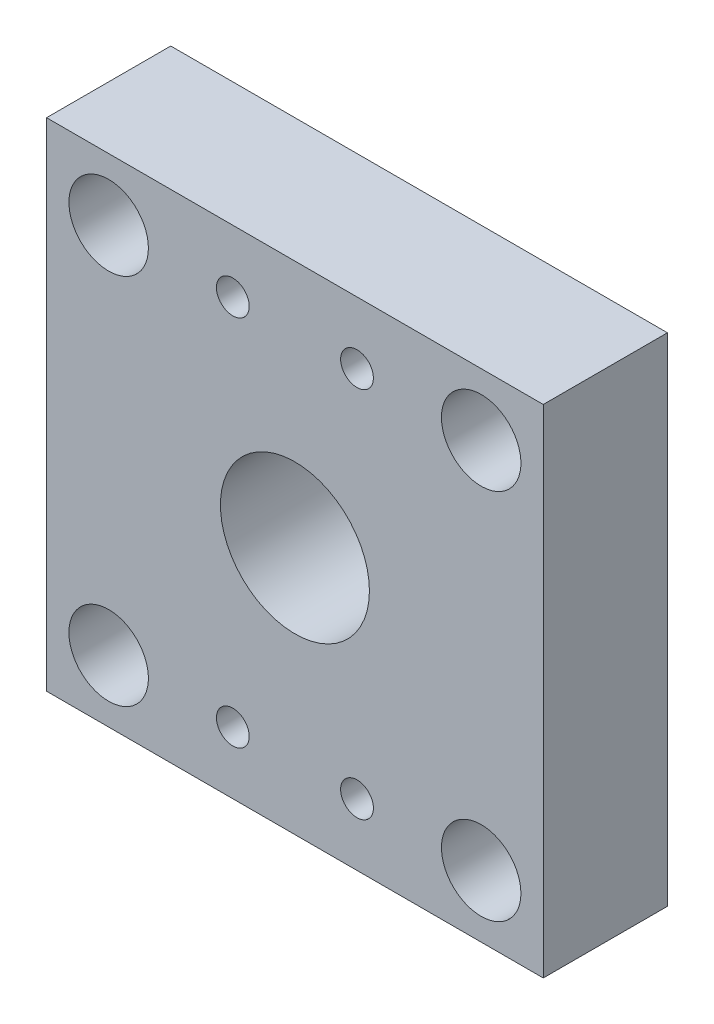
from build123d import *

# Parameters (mm, degrees)
SKETCH1_W           = 50.8
SKETCH1_H           = 50.8
BOSS_EXTRUDE1_DEPTH = 12.7
SKETCH2_R           = 7.62
CUT_EXTRUDE1_DEPTH  = 13.7
SKETCH3_R           = 4.064
CUT_EXTRUDE2_DEPTH  = 13.7
SKETCH4_R           = 1.6764
CUT_EXTRUDE3_DEPTH  = 13.7


with BuildPart() as part:
    # Sketch1 → Boss-Extrude1 (new body)
    with BuildSketch(Plane.XY):
        with Locations((25.4, 25.4)):
            Rectangle(SKETCH1_W, SKETCH1_H)
    extrude(amount=BOSS_EXTRUDE1_DEPTH)

    # Sketch2 → Cut-Extrude1 (cut, through all)
    with BuildSketch(Plane.XY.offset(12.7)):
        with Locations((25.4, 25.4)):
            Circle(SKETCH2_R)
    extrude(amount=-CUT_EXTRUDE1_DEPTH, mode=Mode.SUBTRACT)

    # Sketch3 → Cut-Extrude2 (cut, through all)
    with BuildSketch(Plane.XY.offset(12.7)):
        with Locations((6.35, 44.45)):
            Circle(SKETCH3_R)
        with Locations((6.35, 6.35)):
            Circle(SKETCH3_R)
        with Locations((44.45, 44.45)):
            Circle(SKETCH3_R)
        with Locations((44.45, 6.35)):
            Circle(SKETCH3_R)
    extrude(amount=-CUT_EXTRUDE2_DEPTH, mode=Mode.SUBTRACT)

    # Sketch4 → Cut-Extrude3 (cut, through all)
    with BuildSketch(Plane.XY.offset(12.7)):
        with Locations((19.05, 44.45)):
            Circle(SKETCH4_R)
        with Locations((31.75, 44.45)):
            Circle(SKETCH4_R)
        with Locations((19.05, 6.35)):
            Circle(SKETCH4_R)
        with Locations((31.75, 6.35)):
            Circle(SKETCH4_R)
    extrude(amount=-CUT_EXTRUDE3_DEPTH, mode=Mode.SUBTRACT)


solid = part.part
